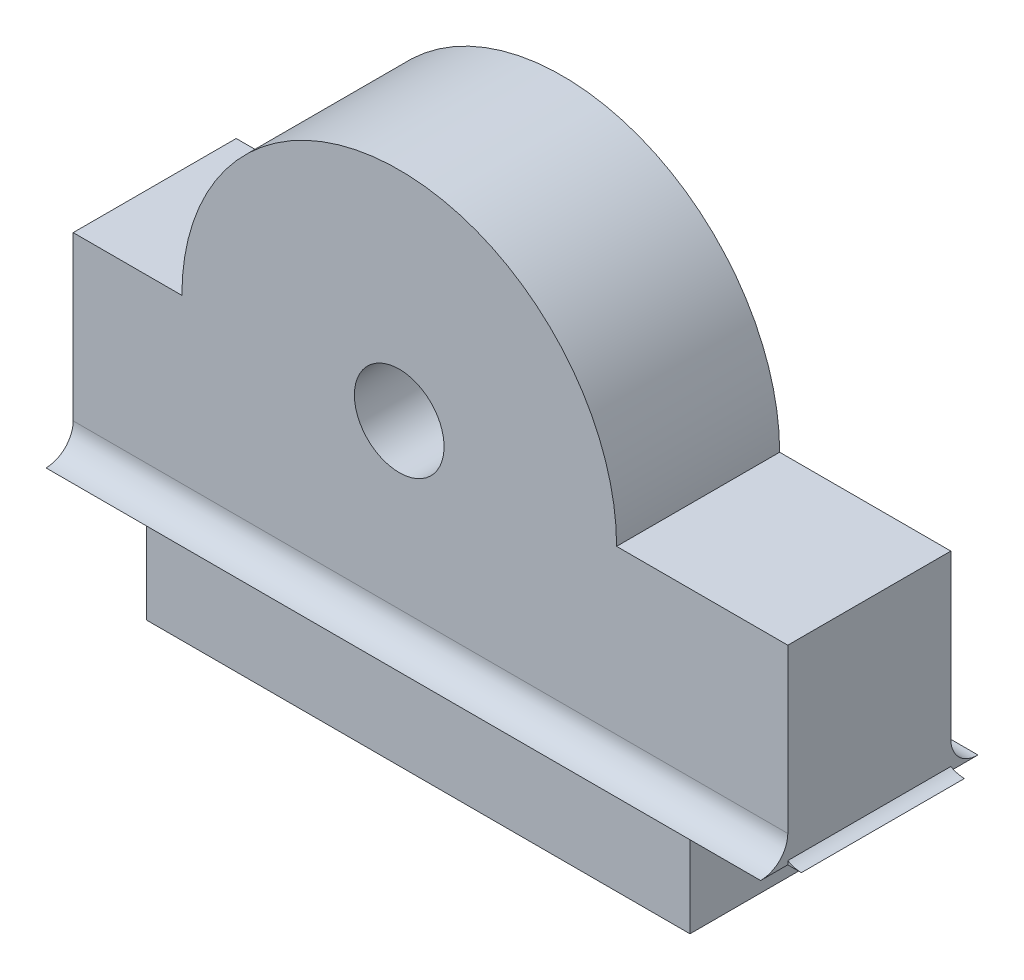
from build123d import *

# Parameters (mm, degrees)
SKETCH1_R           = 2.9
BOSS_EXTRUDE1_DEPTH = 6
BOSS_EXTRUDE2_DEPTH = 26.3
BOSS_EXTRUDE3_DEPTH = 6
SKETCH5_R           = 2.9
SKETCH5_R_2         = 1.65
BOSS_EXTRUDE4_DEPTH = 3


with BuildPart() as part:
    # Sketch1 → Boss-Extrude1 (new body)
    with BuildSketch(Plane.XY):
        with BuildLine():
            Line((0, 0), (20, 0))
            Line((20, 0), (20, 4))
            Line((20, 4), (23.6, 4))
            Line((23.6, 4), (23.6, 11))
            Line((23.6, 11), (17.3, 11))
            ThreePointArc((17.3, 11), (9.3, 19), (1.3, 11))
            Line((1.3, 11), (-2.7, 11))
            Line((-2.7, 11), (-2.7, 4))
            Line((-2.7, 4), (0, 4))
            Line((0, 4), (0, 0))
        make_face()
        with Locations((9.3, 11)):
            Circle(SKETCH1_R, mode=Mode.SUBTRACT)
    extrude(amount=BOSS_EXTRUDE1_DEPTH)

    # Sketch2 → Boss-Extrude2 (add)
    with BuildSketch(Plane.ZY.offset(2.7)):
        with BuildLine():
            Line((6, 4), (6, 5))
            ThreePointArc((6, 5), (6.292893219, 4.292893219), (7, 4))
            Line((7, 4), (6, 4))
        make_face()
        with BuildLine():
            Line((0, 4), (-1, 4))
            ThreePointArc((-1, 4), (-0.292893219, 4.292893219), (0, 5))
            Line((0, 5), (0, 4))
        make_face()
    extrude(amount=-BOSS_EXTRUDE2_DEPTH)

    # Sketch4 → Boss-Extrude3 (add)
    with BuildSketch(Plane.XY.offset(6)):
        with BuildLine():
            Line((23.1, 4), (23.1, 5))
            ThreePointArc((23.1, 5), (23.392893219, 4.292893219), (24.1, 4))
            Line((24.1, 4), (23.1, 4))
        make_face()
        with BuildLine():
            Line((-1.5, 4), (-2.5, 4))
            ThreePointArc((-2.5, 4), (-1.792893219, 4.292893219), (-1.5, 5))
            Line((-1.5, 5), (-1.5, 4))
        make_face()
    extrude(amount=-BOSS_EXTRUDE3_DEPTH)

    # Sketch5 → Boss-Extrude4 (add)
    with BuildSketch(Plane(origin=(0, 0, 6), x_dir=(-1, 0, 0), z_dir=(0, 0, -1))):
        with Locations((-9.3, 11)):
            Circle(SKETCH5_R)
        with Locations((-9.3, 11)):
            Circle(SKETCH5_R_2, mode=Mode.SUBTRACT)
    extrude(amount=BOSS_EXTRUDE4_DEPTH)


solid = part.part
